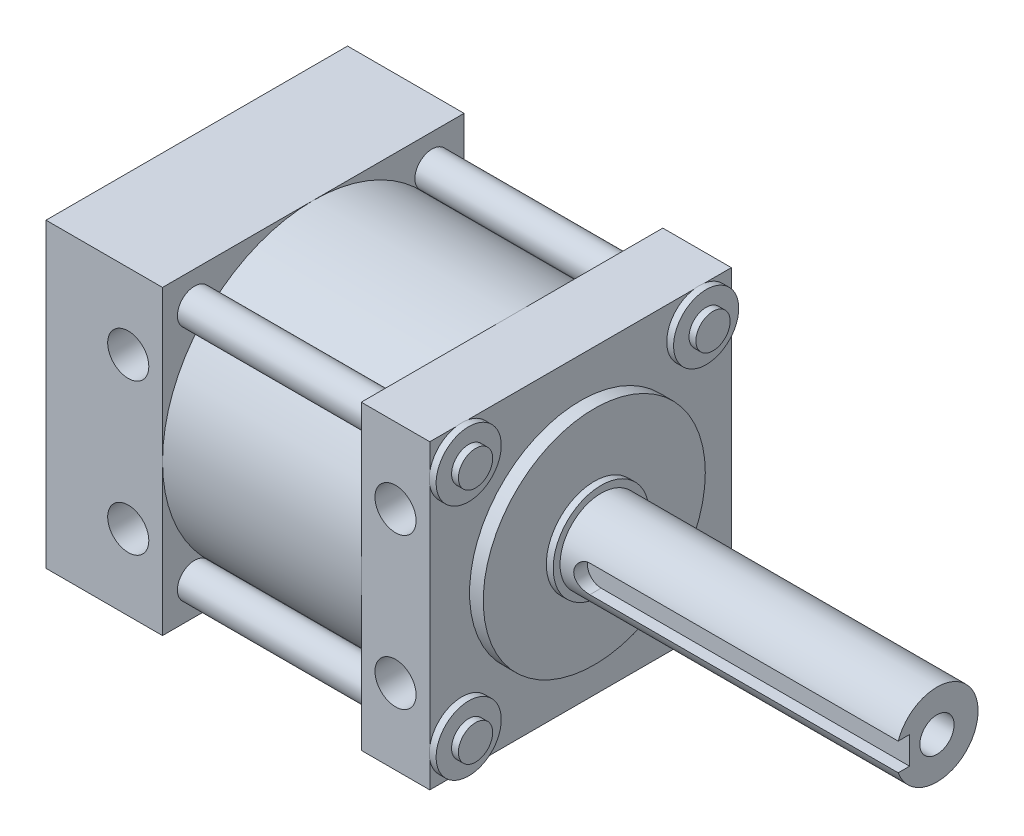
from build123d import *

# Parameters (mm, degrees)
SKETCH1_W                   = 44
SKETCH1_H                   = 44
BOSS_EXTRUDE11_DEPTH        = 10
SKETCH1_16_R                = 22
SKETCH1_16_R_2              = 16.2
SKETCH1_16_R_3              = 7
SKETCH1_16_R_4              = 6
SKETCH1_16_R_5              = 2
BOSS_EXTRUDE13_DEPTH        = 39
SKETCH1_18_R                = 6
SKETCH1_18_R_2              = 2
BOSS_EXTRUDE14_DEPTH        = 52
SKETCH1_19_R                = 7
SKETCH1_19_R_2              = 6
BOSS_EXTRUDE15_DEPTH        = 3
SKETCH1_20_R                = 16.2
SKETCH1_20_R_2              = 7
BOSS_EXTRUDE16_DEPTH        = 2
SKETCH6_W                   = 44
SKETCH6_H                   = 44
BOSS_EXTRUDE17_DEPTH        = 17
SKETCH1_25_R                = 2.5
BOSS_EXTRUDE25_DEPTH        = 2
BOSS_EXTRUDE25_DEPTH_BACK   = 39
BOSS_EXTRUDE25_2_DEPTH      = 2
BOSS_EXTRUDE25_2_DEPTH_BACK = 39
BOSS_EXTRUDE25_3_DEPTH      = 2
BOSS_EXTRUDE25_3_DEPTH_BACK = 39
BOSS_EXTRUDE25_4_DEPTH      = 2
BOSS_EXTRUDE25_4_DEPTH_BACK = 39
SKETCH8_R                   = 3
CUT_EXTRUDE2_DEPTH          = 12
SKETCH9_R                   = 3
CUT_EXTRUDE3_DEPTH          = 12
SKETCH12_W                  = 2
SKETCH12_H                  = 4
CUT_EXTRUDE4_DEPTH          = 45
SKETCH11_R                  = 2.5
CUT_EXTRUDE5_DEPTH          = 28
CUT_EXTRUDE6_DEPTH          = 28
SKETCH15_R                  = 3
CUT_EXTRUDE7_DEPTH          = 12
SKETCH16_R                  = 3
CUT_EXTRUDE8_DEPTH          = 12
SKETCH10_R                  = 4.75
BOSS_EXTRUDE26_DEPTH        = 1
CUT_EXTRUDE9_START          = -56
SKETCH1_30_R                = 2.5
CUT_EXTRUDE9_DEPTH          = 10
SKETCH17_R                  = 21
SKETCH17_R_2                = 2
SKETCH17_R_3                = 7.5
CUT_EXTRUDE10_DEPTH         = 7
SKETCH17_3_R                = 7.5
SKETCH17_3_R_2              = 2
CUT_EXTRUDE11_DEPTH         = 20


with BuildPart() as part:
    # Sketch1 → Boss-Extrude11 (new body)
    with BuildSketch(Plane(origin=(0, 0, 0), x_dir=(0, 0, -1), z_dir=(1, 0, 0))):
        Rectangle(SKETCH1_W, SKETCH1_H)
    extrude(amount=-BOSS_EXTRUDE11_DEPTH)

    # Sketch1_16 → Boss-Extrude13 (add)
    with BuildSketch(Plane(origin=(0, 0, 0), x_dir=(0, 0, -1), z_dir=(1, 0, 0))):
        Circle(SKETCH1_16_R)
        Circle(SKETCH1_16_R_2, mode=Mode.SUBTRACT)
        Circle(SKETCH1_16_R_2)
        Circle(SKETCH1_16_R_3, mode=Mode.SUBTRACT)
        Circle(SKETCH1_16_R_3)
        Circle(SKETCH1_16_R_4, mode=Mode.SUBTRACT)
        Circle(SKETCH1_16_R_4)
        Circle(SKETCH1_16_R_5, mode=Mode.SUBTRACT)
        Circle(SKETCH1_16_R_5)
    extrude(amount=-BOSS_EXTRUDE13_DEPTH)

    # Sketch1_18 → Boss-Extrude14 (add)
    with BuildSketch(Plane(origin=(0, 0, 0), x_dir=(0, 0, -1), z_dir=(1, 0, 0))):
        Circle(SKETCH1_18_R)
        Circle(SKETCH1_18_R_2, mode=Mode.SUBTRACT)
        Circle(SKETCH1_18_R_2)
    extrude(amount=BOSS_EXTRUDE14_DEPTH)

    # Sketch1_19 → Boss-Extrude15 (add)
    with BuildSketch(Plane(origin=(0, 0, 0), x_dir=(0, 0, -1), z_dir=(1, 0, 0))):
        Circle(SKETCH1_19_R)
        Circle(SKETCH1_19_R_2, mode=Mode.SUBTRACT)
    extrude(amount=BOSS_EXTRUDE15_DEPTH)

    # Sketch1_20 → Boss-Extrude16 (add)
    with BuildSketch(Plane(origin=(0, 0, 0), x_dir=(0, 0, -1), z_dir=(1, 0, 0))):
        Circle(SKETCH1_20_R)
        Circle(SKETCH1_20_R_2, mode=Mode.SUBTRACT)
    extrude(amount=BOSS_EXTRUDE16_DEPTH)

    # Sketch6 → Boss-Extrude17 (add)
    with BuildSketch(Plane.ZY.offset(39)):
        Rectangle(SKETCH6_W, SKETCH6_H)
    extrude(amount=BOSS_EXTRUDE17_DEPTH)

    # Sketch8 → Cut-Extrude2 (cut)
    with BuildSketch(Plane.XY.offset(22)):
        with Locations((-44, 11)):
            Circle(SKETCH8_R)
        with Locations((-44, -11)):
            Circle(SKETCH8_R)
    extrude(amount=-CUT_EXTRUDE2_DEPTH, mode=Mode.SUBTRACT)

    # Sketch9 → Cut-Extrude3 (cut)
    with BuildSketch(Plane.XY.offset(22)):
        with Locations((-5, 11)):
            Circle(SKETCH9_R)
        with Locations((-5, -11)):
            Circle(SKETCH9_R)
    extrude(amount=-CUT_EXTRUDE3_DEPTH, mode=Mode.SUBTRACT)

    # Sketch12 → Cut-Extrude4 (cut)
    with BuildSketch(Plane(origin=(52, 0, 0), x_dir=(0, 0, -1), z_dir=(1, 0, 0))):
        with Locations((-5, 0)):
            Rectangle(SKETCH12_W, SKETCH12_H)
    extrude(amount=-CUT_EXTRUDE4_DEPTH, mode=Mode.SUBTRACT)

    # Sketch11 → Cut-Extrude5 (cut)
    with BuildSketch(Plane(origin=(52, 0, 0), x_dir=(0, 0, -1), z_dir=(1, 0, 0))):
        Circle(SKETCH11_R)
    extrude(amount=-CUT_EXTRUDE5_DEPTH, mode=Mode.SUBTRACT)

    # Sketch13 → Cut-Extrude6 (cut)
    with BuildSketch(Plane.XY.offset(4)):
        with BuildLine():
            Line((7, 2), (7, -2))
            ThreePointArc((7, -2), (5, 0), (7, 2))
        make_face()
    extrude(amount=CUT_EXTRUDE6_DEPTH, mode=Mode.SUBTRACT)

    # Sketch15 → Cut-Extrude7 (cut)
    with BuildSketch(Plane(origin=(0, 0, -22), x_dir=(-1, 0, 0), z_dir=(0, 0, -1))):
        with Locations((5, 11)):
            Circle(SKETCH15_R)
        with Locations((5, -11)):
            Circle(SKETCH15_R)
    extrude(amount=-CUT_EXTRUDE7_DEPTH, mode=Mode.SUBTRACT)

    # Sketch16 → Cut-Extrude8 (cut)
    with BuildSketch(Plane(origin=(0, 0, -22), x_dir=(-1, 0, 0), z_dir=(0, 0, -1))):
        with Locations((44, 11)):
            Circle(SKETCH16_R)
        with Locations((44, -11)):
            Circle(SKETCH16_R)
    extrude(amount=-CUT_EXTRUDE8_DEPTH, mode=Mode.SUBTRACT)

    # Sketch1_30 → Cut-Extrude9 (cut)
    with BuildSketch(Plane(origin=(0, 0, 0), x_dir=(0, 0, -1), z_dir=(1, 0, 0)).offset(CUT_EXTRUDE9_START)):
        with Locations((-17.324116139, 17.324116139)):
            Circle(SKETCH1_30_R)
        with Locations((-17.324116139, -17.324116139)):
            Circle(SKETCH1_30_R)
        with Locations((17.324116139, 17.324116139)):
            Circle(SKETCH1_30_R)
        with Locations((17.324116139, -17.324116139)):
            Circle(SKETCH1_30_R)
    extrude(amount=CUT_EXTRUDE9_DEPTH, mode=Mode.SUBTRACT)

    # Sketch17 → Cut-Extrude10 (cut)
    with BuildSketch(Plane.ZY.offset(56)):
        Circle(SKETCH17_R)
        with Locations((-14.5, 0)):
            Circle(SKETCH17_R_2, mode=Mode.SUBTRACT)
        with Locations((14.5, 0)):
            Circle(SKETCH17_R_2, mode=Mode.SUBTRACT)
        Circle(SKETCH17_R_3, mode=Mode.SUBTRACT)
        with Locations((-14.5, 0)):
            Circle(SKETCH17_R_2)
        Circle(SKETCH17_R_3)
        with Locations((14.5, 0)):
            Circle(SKETCH17_R_2)
    extrude(amount=-CUT_EXTRUDE10_DEPTH, mode=Mode.SUBTRACT)

    # Sketch17_3 → Cut-Extrude11 (cut)
    with BuildSketch(Plane.ZY.offset(56)):
        Circle(SKETCH17_3_R)
        with Locations((-14.5, 0)):
            Circle(SKETCH17_3_R_2)
        with Locations((14.5, 0)):
            Circle(SKETCH17_3_R_2)
    extrude(amount=-CUT_EXTRUDE11_DEPTH, mode=Mode.SUBTRACT)


with BuildPart() as body_2:
    # Sketch1_25 → Boss-Extrude25 (new body, two sides)
    with BuildSketch(Plane(origin=(0, 0, 0), x_dir=(0, 0, -1), z_dir=(1, 0, 0))) as boss_extrude25_sk:
        with Locations((-17.324116139, 17.324116139)):
            Circle(SKETCH1_25_R)
    extrude(amount=BOSS_EXTRUDE25_DEPTH)
    extrude(boss_extrude25_sk.sketch, amount=-BOSS_EXTRUDE25_DEPTH_BACK)



with BuildPart() as body_3:
    # Sketch1_25 → Boss-Extrude25 2 (new body, two sides)
    with BuildSketch(Plane(origin=(0, 0, 0), x_dir=(0, 0, -1), z_dir=(1, 0, 0))) as boss_extrude25_2_sk:
        with Locations((17.324116139, -17.324116139)):
            Circle(SKETCH1_25_R)
    extrude(amount=BOSS_EXTRUDE25_2_DEPTH)
    extrude(boss_extrude25_2_sk.sketch, amount=-BOSS_EXTRUDE25_2_DEPTH_BACK)


with BuildPart() as body_4:
    # Sketch1_25 → Boss-Extrude25 3 (new body, two sides)
    with BuildSketch(Plane(origin=(0, 0, 0), x_dir=(0, 0, -1), z_dir=(1, 0, 0))) as boss_extrude25_3_sk:
        with Locations((-17.324116139, -17.324116139)):
            Circle(SKETCH1_25_R)
    extrude(amount=BOSS_EXTRUDE25_3_DEPTH)
    extrude(boss_extrude25_3_sk.sketch, amount=-BOSS_EXTRUDE25_3_DEPTH_BACK)


with BuildPart() as body_5:
    # Sketch1_25 → Boss-Extrude25 4 (new body, two sides)
    with BuildSketch(Plane(origin=(0, 0, 0), x_dir=(0, 0, -1), z_dir=(1, 0, 0))) as boss_extrude25_4_sk:
        with Locations((17.324116139, 17.324116139)):
            Circle(SKETCH1_25_R)
    extrude(amount=BOSS_EXTRUDE25_4_DEPTH)
    extrude(boss_extrude25_4_sk.sketch, amount=-BOSS_EXTRUDE25_4_DEPTH_BACK)


with BuildPart() as body_2_1:
    add(body_2.part)

    add(body_3.part)  # Boss-Extrude26 merges body 3

    add(body_4.part)  # Boss-Extrude26 merges body 4

    add(body_5.part)  # Boss-Extrude26 merges body 5
    # Sketch10 → Boss-Extrude26 (add)
    with BuildSketch(Plane(origin=(0, 0, 0), x_dir=(0, 0, -1), z_dir=(1, 0, 0))):
        with Locations((-17.324116139, 17.324116139)):
            Circle(SKETCH10_R)
        with Locations((17.324116139, 17.324116139)):
            Circle(SKETCH10_R)
        with Locations((17.324116139, -17.324116139)):
            Circle(SKETCH10_R)
        with Locations((-17.324116139, -17.324116139)):
            Circle(SKETCH10_R)
    extrude(amount=BOSS_EXTRUDE26_DEPTH)


solid = Compound([part.part, body_2_1.part])
